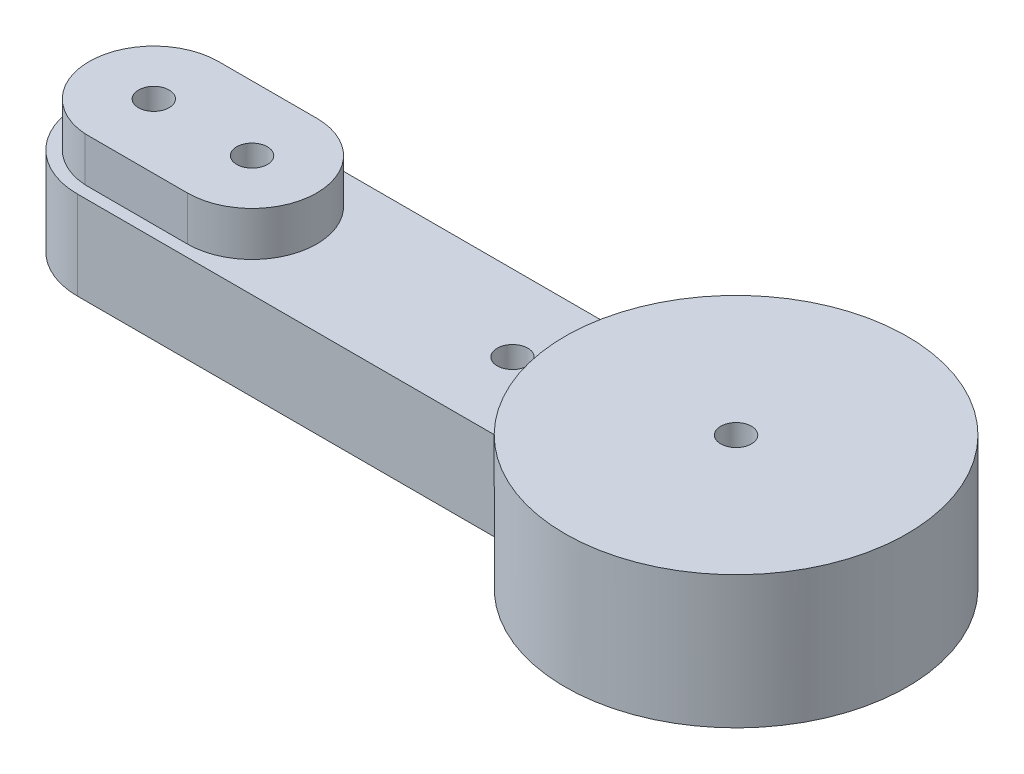
from build123d import *

# Parameters (mm, degrees)
SKETCH1_R           = 0.625
BOSS_EXTRUDE1_DEPTH = 3.6
SKETCH2_R           = 0.625
BOSS_EXTRUDE2_DEPTH = 1.8


with BuildPart() as part:
    # Sketch1 → Boss-Extrude1 (new body)
    with BuildSketch(Plane(origin=(0, 0, 0), x_dir=(1, 0, 0), z_dir=(0, 1, 0))):
        with BuildLine():
            Line((-23.7, 3.107973286), (-6.230065085, 3.107973286))
            ThreePointArc((-6.230065085, 3.107973286), (6.962270385, 0), (-6.230065085, -3.107973286))
            Line((-6.230065085, -3.107973286), (-23.7, -3.107973286))
            ThreePointArc((-23.7, -3.107973286), (-26.807973286, 0), (-23.7, 3.107973286))
        make_face()
        with Locations((-23.7, 0)):
            Circle(SKETCH1_R, mode=Mode.SUBTRACT)
        with Locations((-19.7, 0)):
            Circle(SKETCH1_R, mode=Mode.SUBTRACT)
        with Locations((-9.1, 0)):
            Circle(SKETCH1_R, mode=Mode.SUBTRACT)
        Circle(SKETCH1_R, mode=Mode.SUBTRACT)
    extrude(amount=BOSS_EXTRUDE1_DEPTH)

    # Sketch2 → Boss-Extrude2 (add)
    with BuildSketch(Plane(origin=(0, 3.6, 0), x_dir=(1, 0, 0), z_dir=(0, 1, 0))):
        with BuildLine():
            ThreePointArc((-19.7, -2.633766086), (-17.066233914, 0), (-19.7, 2.633766086))
            Line((-19.7, 2.633766086), (-23.7, 2.633766086))
            ThreePointArc((-23.7, 2.633766086), (-26.332441924, 0.083506378), (-23.866928789, -2.628470768))
            Line((-23.866928789, -2.628470768), (-23.539752243, -2.628886543))
            Line((-23.539752243, -2.628886543), (-19.706693951, -2.63375758))
            Line((-19.706693951, -2.63375758), (-19.7, -2.633766086))
        make_face()
        with Locations((-19.7, 0)):
            Circle(SKETCH2_R, mode=Mode.SUBTRACT)
        with Locations((-23.7, 0)):
            Circle(SKETCH2_R, mode=Mode.SUBTRACT)
        with BuildLine():
            ThreePointArc((-6.230065085, -3.107973286), (1.596529247, -6.776747249), (6.962270385, 0))
            ThreePointArc((6.962270385, 0), (1.596529247, 6.776747249), (-6.230065085, 3.107973286))
            ThreePointArc((-6.230065085, 3.107973286), (-6.962270385, 0), (-6.230065085, -3.107973286))
        make_face()
        Circle(SKETCH2_R, mode=Mode.SUBTRACT)
    extrude(amount=BOSS_EXTRUDE2_DEPTH)


solid = part.part
